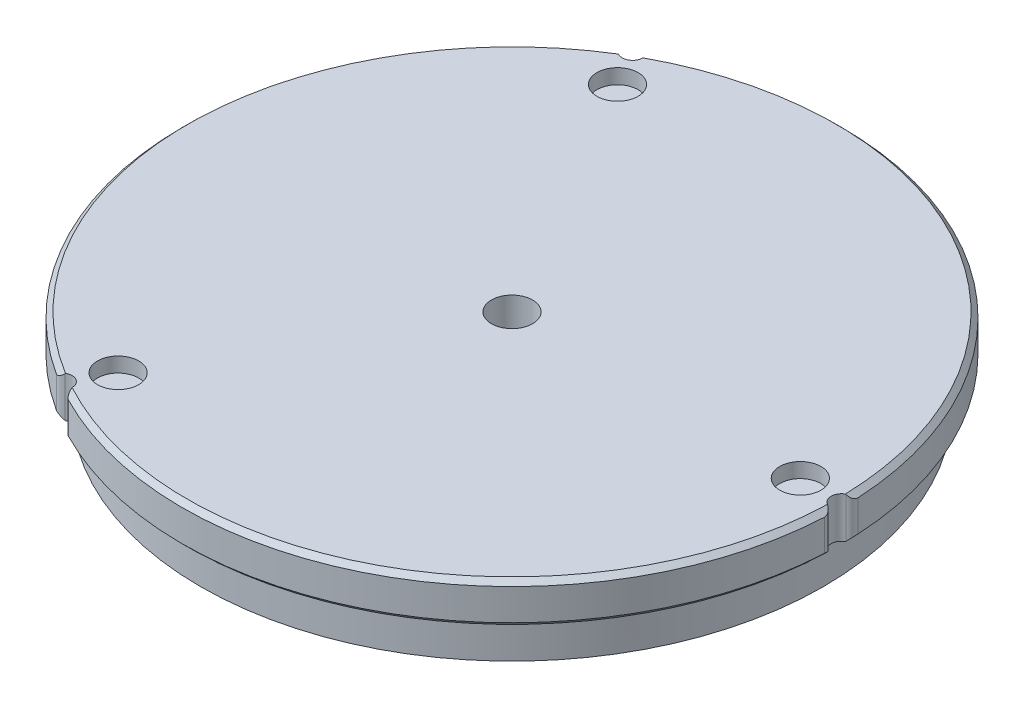
from build123d import *

# Parameters (mm, degrees)
SKETCH1_R               = 50.8
BOSS_EXTRUDE1_DEPTH     = 6.35
SKETCH2_R               = 3.175
CUT_EXTRUDE1_DEPTH      = 2.286
SKETCH3_R               = 3.175
CUT_EXTRUDE2_DEPTH      = 1
CUT_EXTRUDE2_DEPTH_BACK = 7.35
SKETCH4_R               = 1.5875
CUT_EXTRUDE3_DEPTH      = 7.35
CHAMFER1_SIZE           = 0.762
FILLET1_R               = 1.27
SKETCH5_R               = 48
SKETCH5_R_2             = 46
BOSS_EXTRUDE2_DEPTH     = 6.35


with BuildPart() as part:
    # Sketch1 → Boss-Extrude1 (new body)
    with BuildSketch(Plane(origin=(0, 0, 0), x_dir=(1, 0, 0), z_dir=(0, 1, 0))):
        Circle(SKETCH1_R)
    extrude(amount=BOSS_EXTRUDE1_DEPTH)

    # Sketch2 → Cut-Extrude1 (cut)
    with BuildSketch(Plane(origin=(0, 6.35, 0), x_dir=(1, 0, 0), z_dir=(0, 1, 0))):
        with Locations((-22.225, -38.494829198)):
            Circle(SKETCH2_R)
        with Locations((-22.225, 38.494829198)):
            Circle(SKETCH2_R)
        with Locations((44.45, 0)):
            Circle(SKETCH2_R)
    extrude(amount=-CUT_EXTRUDE1_DEPTH, mode=Mode.SUBTRACT)

    # Sketch3 → Cut-Extrude2 (cut, two sides)
    with BuildSketch(Plane(origin=(0, 6.35, 0), x_dir=(1, 0, 0), z_dir=(0, 1, 0))) as cut_extrude2_sk:
        Circle(SKETCH3_R)
    extrude(amount=CUT_EXTRUDE2_DEPTH, mode=Mode.SUBTRACT)
    extrude(cut_extrude2_sk.sketch, amount=-CUT_EXTRUDE2_DEPTH_BACK, mode=Mode.SUBTRACT)

    # Sketch4 → Cut-Extrude3 (cut, through all)
    with BuildSketch(Plane.XZ):
        with Locations((50.8, 0)):
            Circle(SKETCH4_R)
        with Locations((-25.4, 43.994090512)):
            Circle(SKETCH4_R)
        with Locations((-25.4, -43.994090512)):
            Circle(SKETCH4_R)
    extrude(amount=-CUT_EXTRUDE3_DEPTH, mode=Mode.SUBTRACT)

    # Chamfer1
    chamfer1_edges = [part.edges().sort_by_distance(p)[0] for p in [
        (25.4, 0, -43.994090512),
        (-50.8, 0, 0),
        (25.4, 0, 43.994090512),
        (25.4, 6.35, -43.994090512),
        (-50.8, 6.35, 0),
        (25.4, 6.35, 43.994090512),
    ]]
    chamfer(chamfer1_edges, length=CHAMFER1_SIZE)

    # Fillet1
    fillet1_edges = [part.edges().sort_by_distance(p)[0] for p in [
        (-24.012950162, 3.175, 44.766262124),
        (-26.76224515, 3.175, 43.178955922),
        (50.775195313, 3.175, -1.587306202),
        (50.775195313, 3.175, 1.587306202),
        (-24.012950162, 3.175, -44.766262124),
        (-26.76224515, 3.175, -43.178955922),
    ]]
    fillet(fillet1_edges, radius=FILLET1_R)

    # Sketch5 → Boss-Extrude2 (add)
    with BuildSketch(Plane.XZ):
        Circle(SKETCH5_R)
        Circle(SKETCH5_R_2, mode=Mode.SUBTRACT)
    extrude(amount=BOSS_EXTRUDE2_DEPTH)


solid = part.part
